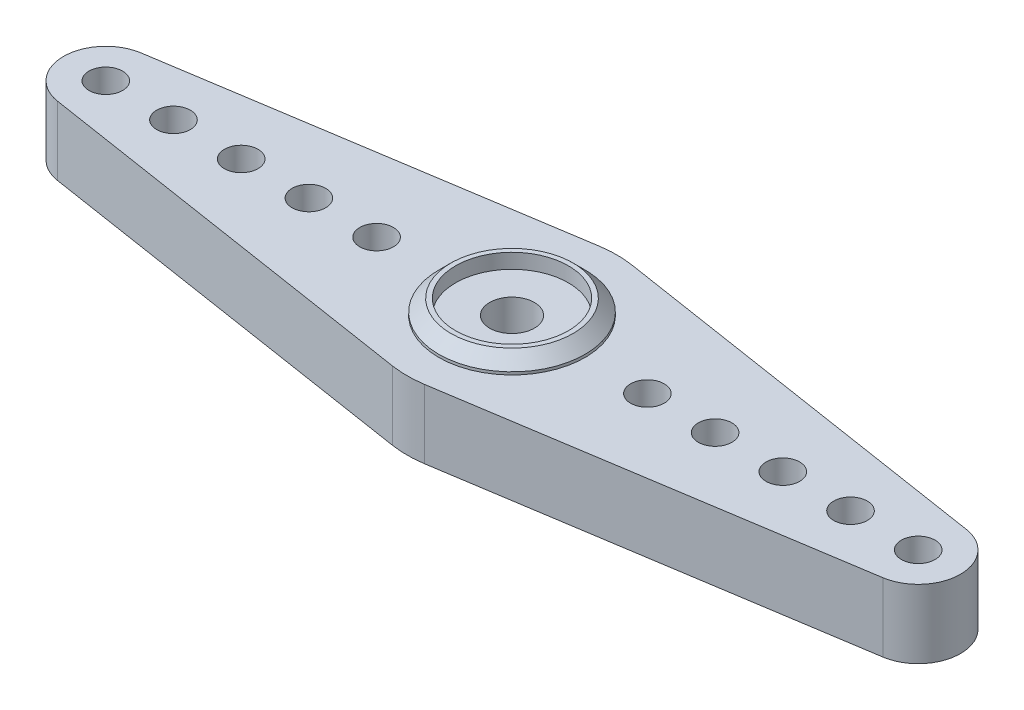
from build123d import *

# Parameters (mm, degrees)
SKETCH1_R           = 1.651
SKETCH1_R_2         = 1.2446
BOSS_EXTRUDE1_DEPTH = 5.08
SKETCH2_R           = 5.40385
SKETCH2_R_2         = 4.1656
BOSS_EXTRUDE2_DEPTH = 1.0922
CHAMFER1_SIZE       = 0.889
SKETCH4_R           = 5.4102
SKETCH4_R_2         = 4.1656
BOSS_EXTRUDE3_DEPTH = 1.4986
CHAMFER2_SIZE       = 0.254


with BuildPart() as part:
    # Sketch1 → Boss-Extrude1 (new body)
    with BuildSketch(Plane(origin=(0, 0, 0), x_dir=(1, 0, 0), z_dir=(0, 1, 0))):
        with BuildLine():
            Line((-30.503852792, 3.086942476), (-1.192854484, 7.654613457))
            ThreePointArc((-1.192854484, 7.654613457), (0, 7.747), (1.192854484, 7.654613457))
            Line((1.192854484, 7.654613457), (30.503852792, 3.086942476))
            ThreePointArc((30.503852792, 3.086942476), (33.147, 0), (30.503852792, -3.086942476))
            Line((30.503852792, -3.086942476), (1.192854484, -7.654613457))
            ThreePointArc((1.192854484, -7.654613457), (0, -7.747), (-1.192854484, -7.654613457))
            Line((-1.192854484, -7.654613457), (-30.503852792, -3.086942476))
            ThreePointArc((-30.503852792, -3.086942476), (-33.147, 0), (-30.503852792, 3.086942476))
        make_face()
        Circle(SKETCH1_R, mode=Mode.SUBTRACT)
        with Locations((-10.0076, 0)):
            Circle(SKETCH1_R_2, mode=Mode.SUBTRACT)
        with Locations((-15.0114, 0)):
            Circle(SKETCH1_R_2, mode=Mode.SUBTRACT)
        with Locations((-20.0152, 0)):
            Circle(SKETCH1_R_2, mode=Mode.SUBTRACT)
        with Locations((-25.019, 0)):
            Circle(SKETCH1_R_2, mode=Mode.SUBTRACT)
        with Locations((-30.0228, 0)):
            Circle(SKETCH1_R_2, mode=Mode.SUBTRACT)
        with Locations((30.0228, 0)):
            Circle(SKETCH1_R_2, mode=Mode.SUBTRACT)
        with Locations((25.019, 0)):
            Circle(SKETCH1_R_2, mode=Mode.SUBTRACT)
        with Locations((20.0152, 0)):
            Circle(SKETCH1_R_2, mode=Mode.SUBTRACT)
        with Locations((15.0114, 0)):
            Circle(SKETCH1_R_2, mode=Mode.SUBTRACT)
        with Locations((10.0076, 0)):
            Circle(SKETCH1_R_2, mode=Mode.SUBTRACT)
    extrude(amount=BOSS_EXTRUDE1_DEPTH)

    # Sketch2 → Boss-Extrude2 (add)
    with BuildSketch(Plane(origin=(0, 5.08, 0), x_dir=(1, 0, 0), z_dir=(0, 1, 0))):
        Circle(SKETCH2_R)
        Circle(SKETCH2_R_2, mode=Mode.SUBTRACT)
    extrude(amount=BOSS_EXTRUDE2_DEPTH)

    # Chamfer1
    chamfer1_edges = [part.edges().sort_by_distance(p)[0] for p in [
        (-5.40385, 6.1722, 0),
    ]]
    chamfer(chamfer1_edges, length=CHAMFER1_SIZE)

    # Sketch4 → Boss-Extrude3 (add)
    with BuildSketch(Plane.XZ):
        Circle(SKETCH4_R)
        Circle(SKETCH4_R_2, mode=Mode.SUBTRACT)
    extrude(amount=BOSS_EXTRUDE3_DEPTH)

    # Chamfer2
    chamfer2_edges = [part.edges().sort_by_distance(p)[0] for p in [
        (-5.4102, -1.4986, 0),
    ]]
    chamfer(chamfer2_edges, length=CHAMFER2_SIZE)


solid = part.part
